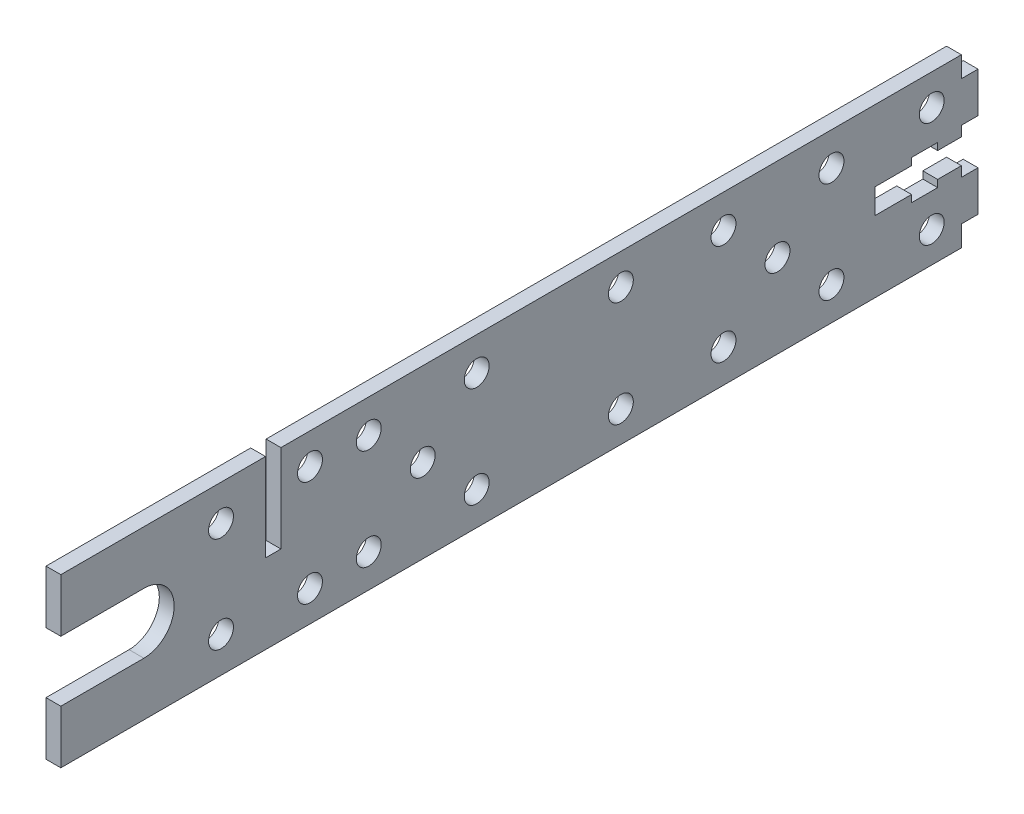
from build123d import *

# Parameters (mm, degrees)
SKETCH1_R           = 2.667
BOSS_EXTRUDE1_DEPTH = 1.5875
SKETCH2_W           = 3.302
SKETCH2_H           = 18.796
CUT_EXTRUDE1_DEPTH  = 4.175


with BuildPart() as part:
    # Sketch1 → Boss-Extrude1 (new body, symmetric)
    with BuildSketch(Plane(origin=(0, 0, 0), x_dir=(0, 0, -1), z_dir=(1, 0, 0))):
        with BuildLine():
            Line((-98.171, 17.907), (94.615, 17.907))
            Line((94.615, 17.907), (94.615, 13.462))
            Line((94.615, 13.462), (98.171, 13.462))
            Line((98.171, 13.462), (98.171, 4.826))
            Line((98.171, 4.826), (94.615, 4.826))
            Line((94.615, 4.826), (94.615, 2.667))
            Line((94.615, 2.667), (89.535, 2.667))
            Line((89.535, 2.667), (89.535, 4.191))
            Line((89.535, 4.191), (83.947, 4.191))
            Line((83.947, 4.191), (83.947, 2.667))
            Line((83.947, 2.667), (76.073, 2.667))
            Line((76.073, 2.667), (76.073, -2.667))
            Line((76.073, -2.667), (83.947, -2.667))
            Line((83.947, -2.667), (83.947, -4.191))
            Line((83.947, -4.191), (89.535, -4.191))
            Line((89.535, -4.191), (89.535, -2.667))
            Line((89.535, -2.667), (94.615, -2.667))
            Line((94.615, -2.667), (94.615, -4.826))
            Line((94.615, -4.826), (98.171, -4.826))
            Line((98.171, -4.826), (98.171, -13.462))
            Line((98.171, -13.462), (94.615, -13.462))
            Line((94.615, -13.462), (94.615, -17.907))
            Line((94.615, -17.907), (-98.171, -17.907))
            Line((-98.171, -17.907), (-98.171, -6.477))
            Line((-98.171, -6.477), (-80.391, -6.477))
            ThreePointArc((-80.391, -6.477), (-73.914, 0), (-80.391, 6.477))
            Line((-80.391, 6.477), (-98.171, 6.477))
            Line((-98.171, 6.477), (-98.171, 17.907))
        make_face()
        with Locations((-63.881, 10.287)):
            Circle(SKETCH1_R, mode=Mode.SUBTRACT)
        with Locations((-63.881, -10.287)):
            Circle(SKETCH1_R, mode=Mode.SUBTRACT)
        with Locations((-44.831, 11.303)):
            Circle(SKETCH1_R, mode=Mode.SUBTRACT)
        with Locations((21.717, 11.303)):
            Circle(SKETCH1_R, mode=Mode.SUBTRACT)
        with Locations((88.265, 11.303)):
            Circle(SKETCH1_R, mode=Mode.SUBTRACT)
        with Locations((88.265, -11.303)):
            Circle(SKETCH1_R, mode=Mode.SUBTRACT)
        with Locations((21.717, -11.303)):
            Circle(SKETCH1_R, mode=Mode.SUBTRACT)
        with Locations((-44.831, -11.303)):
            Circle(SKETCH1_R, mode=Mode.SUBTRACT)
        with Locations((-9.144, 10.795)):
            Circle(SKETCH1_R, mode=Mode.SUBTRACT)
        with Locations((-32.258, 10.795)):
            Circle(SKETCH1_R, mode=Mode.SUBTRACT)
        with Locations((66.802, 10.795)):
            Circle(SKETCH1_R, mode=Mode.SUBTRACT)
        with Locations((43.688, 10.795)):
            Circle(SKETCH1_R, mode=Mode.SUBTRACT)
        with Locations((43.688, -10.795)):
            Circle(SKETCH1_R, mode=Mode.SUBTRACT)
        with Locations((66.802, -10.795)):
            Circle(SKETCH1_R, mode=Mode.SUBTRACT)
        with Locations((-32.258, -10.795)):
            Circle(SKETCH1_R, mode=Mode.SUBTRACT)
        with Locations((-9.144, -10.795)):
            Circle(SKETCH1_R, mode=Mode.SUBTRACT)
        with Locations((-20.701, 0)):
            Circle(SKETCH1_R, mode=Mode.SUBTRACT)
        with Locations((55.245, 0)):
            Circle(SKETCH1_R, mode=Mode.SUBTRACT)
    extrude(amount=BOSS_EXTRUDE1_DEPTH, both=True)

    # Sketch2 → Cut-Extrude1 (cut, through all)
    with BuildSketch(Plane(origin=(1.5875, 0, 0), x_dir=(0, 0, -1), z_dir=(1, 0, 0))):
        with Locations((-52.705, 8.509)):
            Rectangle(SKETCH2_W, SKETCH2_H)
    extrude(amount=-CUT_EXTRUDE1_DEPTH, mode=Mode.SUBTRACT)


solid = part.part
